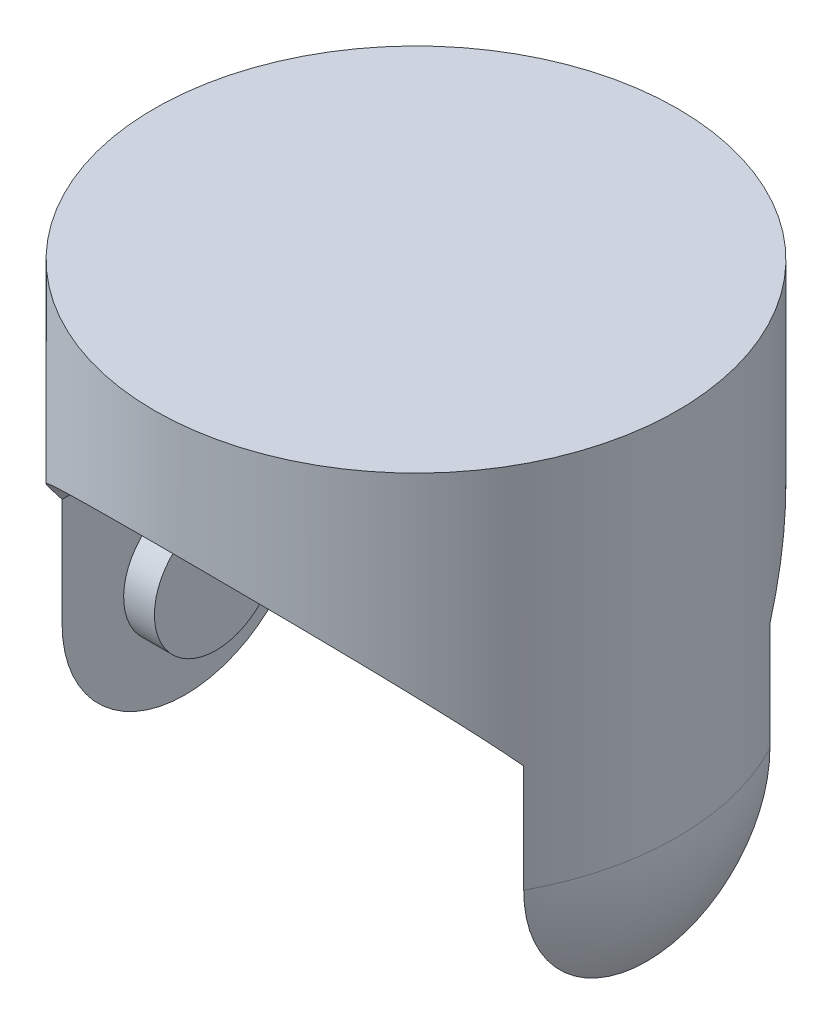
from build123d import *

# Parameters (mm, degrees)
CUT_EXTRUDE1_DEPTH      = 216.9
CUT_EXTRUDE1_DEPTH_BACK = 216.9
SKETCH4_R               = 50.8
BOSS_EXTRUDE1_DEPTH     = 25.4


with BuildPart() as part:
    # Sketch2 → Revolve1 (revolve)
    with BuildSketch(Plane.XY):
        with BuildLine():
            Line((0, 0), (215.9, 0))
            Line((215.9, 0), (215.9, -304.8))
            ThreePointArc((215.9, -304.8), (152.664354058, -457.464354058), (0, -520.7))
            Line((0, -520.7), (0, 0))
        make_face()
    revolve(axis=Axis((0, 0, 0), (0, -1, 0)))

    # Sketch3 → Cut-Extrude1 (cut, two sides)
    with BuildSketch(Plane.XY) as cut_extrude1_sk:
        with BuildLine():
            Line((190.5, -215.9), (190.5, -546.1))
            Line((190.5, -546.1), (-190.5, -546.1))
            Line((-190.5, -546.1), (-190.5, -215.9))
            ThreePointArc((-190.5, -215.9), (0, -94.577593963), (190.5, -215.9))
        make_face()
    extrude(amount=CUT_EXTRUDE1_DEPTH, mode=Mode.SUBTRACT)
    extrude(cut_extrude1_sk.sketch, amount=-CUT_EXTRUDE1_DEPTH_BACK, mode=Mode.SUBTRACT)

    # Sketch4 → Boss-Extrude1 (add)
    with BuildSketch(Plane(origin=(-190.5, 0, 0), x_dir=(0, 0, -1), z_dir=(1, 0, 0))):
        with Locations((0, -311.15)):
            Circle(SKETCH4_R)
    boss_extrude1 = extrude(amount=BOSS_EXTRUDE1_DEPTH)

    # Mirror1: Boss-Extrude1 across plane
    add(boss_extrude1.mirror(Plane(origin=(0, 0, 0), x_dir=(0, 0, 1), z_dir=(1, 0, 0))))


solid = part.part
